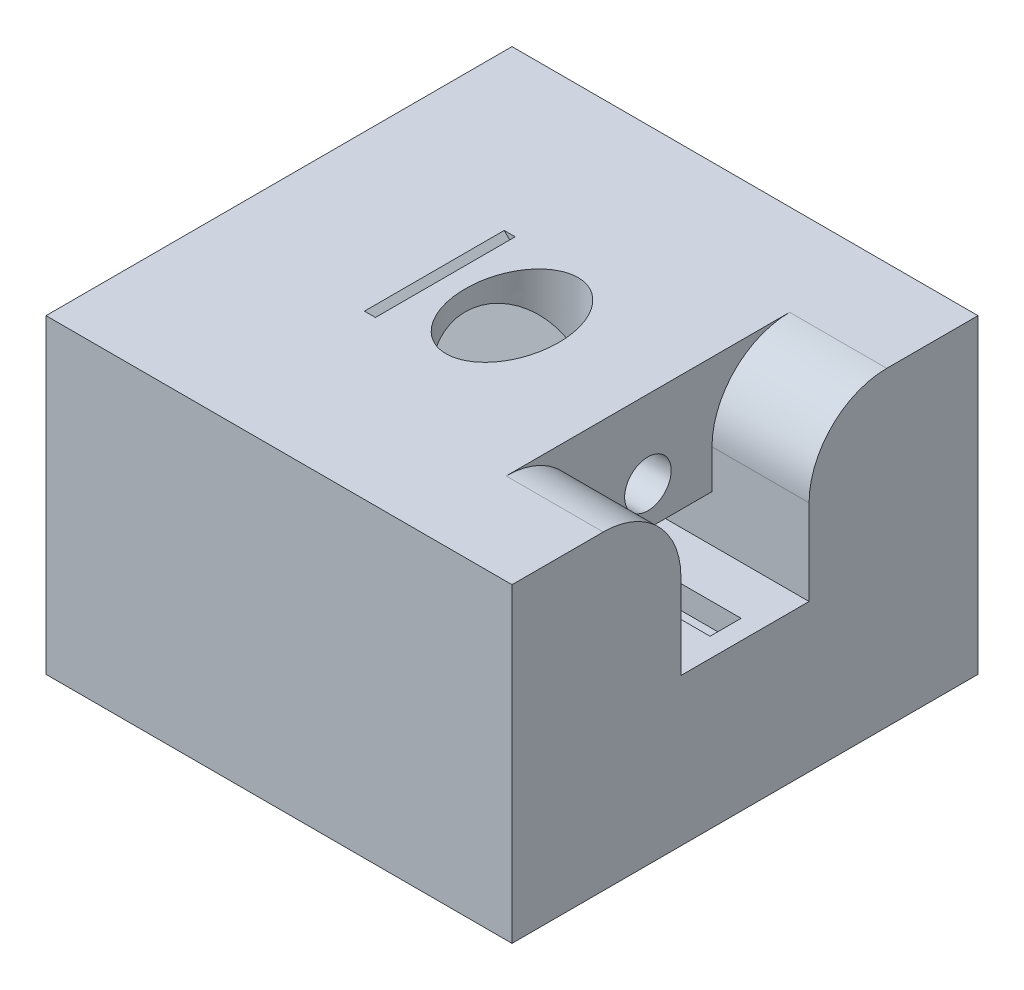
from build123d import *

# Parameters (mm, degrees)
SKETCH1_W               = 60
SKETCH1_H               = 60
BOSS_EXTRUDE1_DEPTH     = 10
SKETCH6_R               = 8.5
SKETCH7_RX              = 8.5
SKETCH7_RY              = 6.01040764
SKETCH8_W               = 60
SKETCH8_H               = 60
SKETCH8_RX              = 8.5
SKETCH8_RY              = 6.01040764
BOSS_EXTRUDE2_DEPTH     = 30
SKETCH9_R               = 3
CUT_EXTRUDE1_DEPTH      = 41
SKETCH10_R              = 3
CUT_EXTRUDE2_DEPTH      = 61
SKETCH11_W              = 16.5
SKETCH11_H              = 21
CUT_EXTRUDE3_DEPTH      = 12.5
SKETCH12_W              = 16.5
SKETCH12_H              = 6
CUT_EXTRUDE4_DEPTH      = 8.5
SKETCH13_W              = 4
SKETCH13_H              = 3
CUT_EXTRUDE5_DEPTH      = 18.5
FILLET1_R               = 10
SKETCH14_W              = 18
SKETCH14_H              = 1
CUT_EXTRUDE7_DEPTH      = 20
CUT_EXTRUDE7_DEPTH_BACK = 14.142136


with BuildPart() as part:
    # Sketch1 → Boss-Extrude1 (new body)
    with BuildSketch(Plane(origin=(0, 0, 0), x_dir=(1, 0, 0), z_dir=(0, 1, 0))):
        Rectangle(SKETCH1_W, SKETCH1_H)
    extrude(amount=BOSS_EXTRUDE1_DEPTH)

    # Sketch6 → Loft1 section 0
    with BuildSketch(Plane(origin=(15, 15, 0), x_dir=(0, 0, -1), z_dir=(0.707106781, 0.707106781, 0))):
        with Locations((0, 21.213203436)):
            Circle(SKETCH6_R)
    # Sketch7 → Loft1 section 1
    with BuildSketch(Plane(origin=(0, 10, 0), x_dir=(1, 0, 0), z_dir=(0, 1, 0))):
        with Locations(Location((0, 0), (0, 0, 90))):
            Ellipse(SKETCH7_RX, SKETCH7_RY)
    loft()

    # Sketch8 → Boss-Extrude2 (add)
    with BuildSketch(Plane(origin=(0, 10, 0), x_dir=(1, 0, 0), z_dir=(0, 1, 0))):
        Rectangle(SKETCH8_W, SKETCH8_H)
        with Locations(Location((0, 0), (0, 0, 90))):
            Ellipse(SKETCH8_RX, SKETCH8_RY, mode=Mode.SUBTRACT)
    extrude(amount=BOSS_EXTRUDE2_DEPTH)

    # Sketch9 → Cut-Extrude1 (cut, through all)
    with BuildSketch(Plane(origin=(0, 40, 0), x_dir=(1, 0, 0), z_dir=(0, 1, 0))):
        Circle(SKETCH9_R)
    extrude(amount=-CUT_EXTRUDE1_DEPTH, mode=Mode.SUBTRACT)

    # Sketch10 → Cut-Extrude2 (cut, through all)
    with BuildSketch(Plane(origin=(30, 0, 0), x_dir=(0, 0, -1), z_dir=(1, 0, 0))):
        with Locations((0, 30)):
            Circle(SKETCH10_R)
    extrude(amount=-CUT_EXTRUDE2_DEPTH, mode=Mode.SUBTRACT)

    # Sketch11 → Cut-Extrude3 (cut)
    with BuildSketch(Plane(origin=(30, 0, 0), x_dir=(0, 0, -1), z_dir=(1, 0, 0))):
        with Locations((0, 29.5)):
            Rectangle(SKETCH11_W, SKETCH11_H)
    extrude(amount=-CUT_EXTRUDE3_DEPTH, mode=Mode.SUBTRACT)

    # Sketch12 → Cut-Extrude4 (cut)
    with BuildSketch(Plane(origin=(17.5, 0, 0), x_dir=(0, 0, -1), z_dir=(1, 0, 0))):
        with Locations((0, 22)):
            Rectangle(SKETCH12_W, SKETCH12_H)
    extrude(amount=-CUT_EXTRUDE4_DEPTH, mode=Mode.SUBTRACT)

    # Sketch13 → Cut-Extrude5 (cut)
    with BuildSketch(Plane(origin=(9, 0, 0), x_dir=(0, 0, -1), z_dir=(1, 0, 0))):
        with Locations((0, 17.5)):
            Rectangle(SKETCH13_W, SKETCH13_H)
    extrude(amount=CUT_EXTRUDE5_DEPTH, mode=Mode.SUBTRACT)

    # Fillet1
    fillet1_edges = [part.edges().sort_by_distance(p)[0] for p in [
        (23.75, 40, 8.25),
        (23.75, 40, -8.25),
    ]]
    fillet(fillet1_edges, radius=FILLET1_R)

    # Sketch14 → Cut-Extrude7 (cut, two sides)
    with BuildSketch(Plane(origin=(-25, 25, 0), x_dir=(0, 0, 1), z_dir=(-0.707106781, 0.707106781, 0))) as cut_extrude7_sk:
        with Locations((0, 21.713203436)):
            Rectangle(SKETCH14_W, SKETCH14_H)
    extrude(amount=CUT_EXTRUDE7_DEPTH, mode=Mode.SUBTRACT)
    extrude(cut_extrude7_sk.sketch, amount=-CUT_EXTRUDE7_DEPTH_BACK, mode=Mode.SUBTRACT)


solid = part.part
